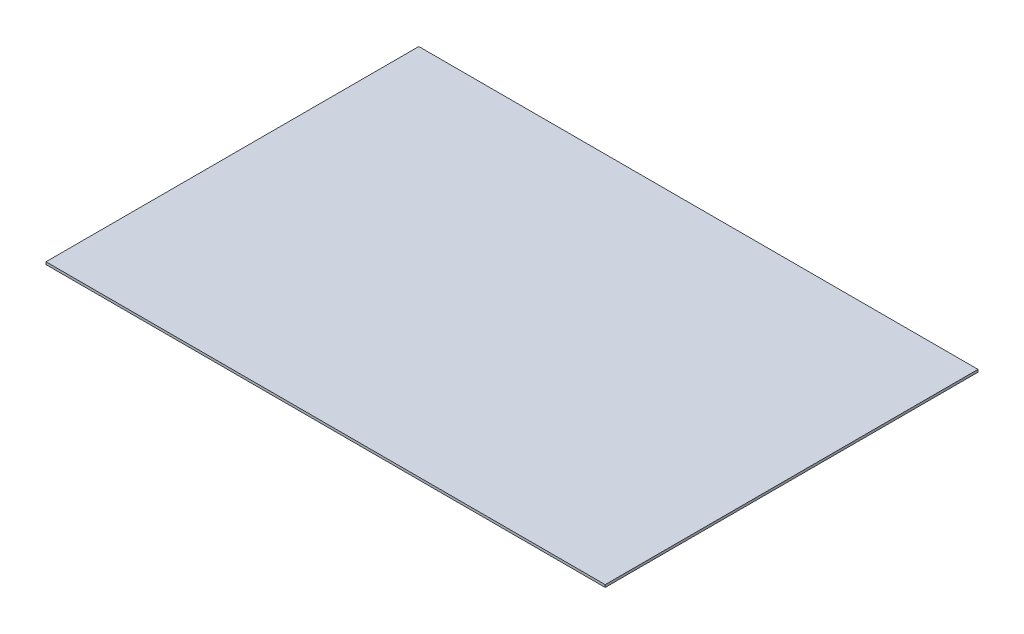
from build123d import *

# Parameters (mm, degrees)
SKETCH1_W           = 228.6
SKETCH1_H           = 152.4
BOSS_EXTRUDE1_DEPTH = 1.016


with BuildPart() as part:
    # Sketch1 → Boss-Extrude1 (new body)
    with BuildSketch(Plane(origin=(0, 0, 0), x_dir=(1, 0, 0), z_dir=(0, 1, 0))):
        Rectangle(SKETCH1_W, SKETCH1_H)
    extrude(amount=BOSS_EXTRUDE1_DEPTH)


solid = part.part
